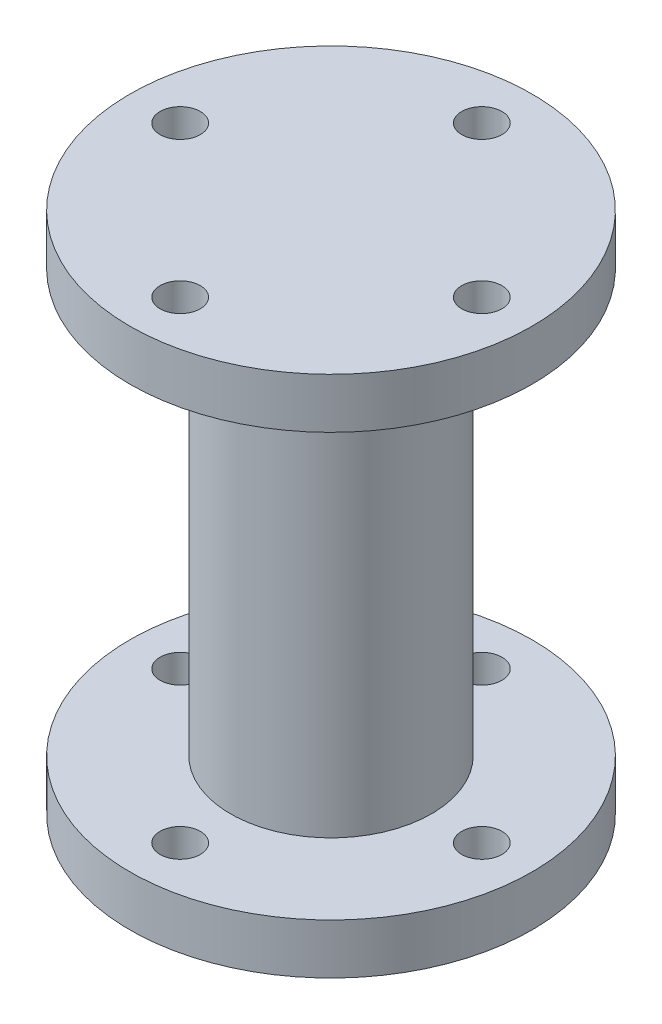
from build123d import *

# Parameters (mm, degrees)
SKETCH1_R           = 20
SKETCH1_R_2         = 2
BOSS_EXTRUDE1_DEPTH = 5
SKETCH2_R           = 10
BOSS_EXTRUDE2_DEPTH = 42
SKETCH3_R           = 20
SKETCH3_R_2         = 10
SKETCH3_R_3         = 2
BOSS_EXTRUDE3_DEPTH = 5


with BuildPart() as part:
    # Sketch1 → Boss-Extrude1 (new body)
    with BuildSketch(Plane(origin=(0, 0, 0), x_dir=(1, 0, 0), z_dir=(0, 1, 0))):
        Circle(SKETCH1_R)
        with Locations((0, 15)):
            Circle(SKETCH1_R_2, mode=Mode.SUBTRACT)
        with Locations((15, 0)):
            Circle(SKETCH1_R_2, mode=Mode.SUBTRACT)
        with Locations((0, -15)):
            Circle(SKETCH1_R_2, mode=Mode.SUBTRACT)
        with Locations((-15, 0)):
            Circle(SKETCH1_R_2, mode=Mode.SUBTRACT)
    extrude(amount=BOSS_EXTRUDE1_DEPTH)

    # Sketch2 → Boss-Extrude2 (add)
    with BuildSketch(Plane.XZ):
        Circle(SKETCH2_R)
    extrude(amount=BOSS_EXTRUDE2_DEPTH)


with BuildPart() as body_2:
    # Sketch3 → Boss-Extrude3 (new body)
    with BuildSketch(Plane.XZ.offset(42)):
        Circle(SKETCH3_R)
        Circle(SKETCH3_R_2, mode=Mode.SUBTRACT)
        with Locations((-15, 0)):
            Circle(SKETCH3_R_3, mode=Mode.SUBTRACT)
        with Locations((0, -15)):
            Circle(SKETCH3_R_3, mode=Mode.SUBTRACT)
        with Locations((15, 0)):
            Circle(SKETCH3_R_3, mode=Mode.SUBTRACT)
        with Locations((0, 15)):
            Circle(SKETCH3_R_3, mode=Mode.SUBTRACT)
    extrude(amount=BOSS_EXTRUDE3_DEPTH)


solid = Compound([part.part, body_2.part])
